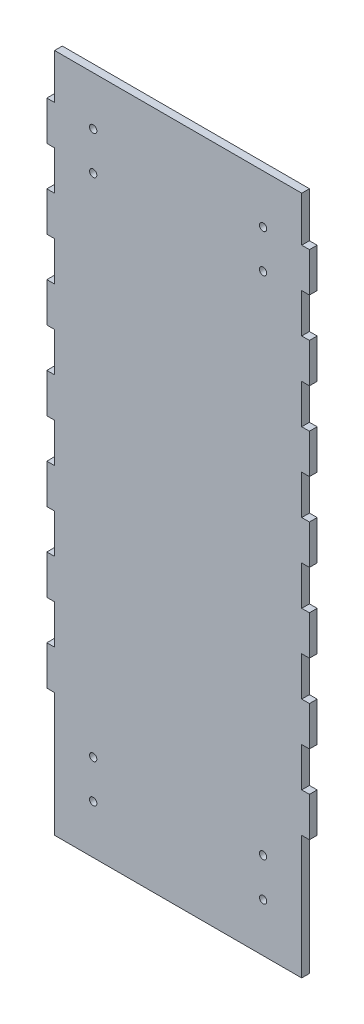
from build123d import *

# Parameters (mm, degrees)
BOSS_EXTRUDE1_DEPTH = 3.175
SKETCH2_R           = 1.5
CUT_EXTRUDE1_DEPTH  = 3.175


with BuildPart() as part:
    # Sketch1 → Boss-Extrude1 (new body)
    with BuildSketch(Plane.XY):
        Polygon((101.6, 279.4), (0, 279.4), (0, 260.883636364), (-3.175, 260.883636364), (-3.175, 244.72), (0, 244.72), (0, 228.563636364), (-3.175, 228.563636364), (-3.175, 212.4), (0, 212.4), (0, 196.243636364), (-3.175, 196.243636364), (-3.175, 180.08), (0, 180.08), (0, 163.923636364), (-3.175, 163.923636364), (-3.175, 147.76), (0, 147.76), (0, 131.603636364), (-3.175, 131.603636364), (-3.175, 115.44), (0, 115.44), (0, 99.283636364), (-3.175, 99.283636364), (-3.175, 83.12), (0, 83.12), (0, 66.963636364), (-3.175, 66.963636364), (-3.175, 50.8), (0, 50.8), (0, 34.64), (0, 0), (101.6, 0), (101.6, 34.64), (101.6, 50.8), (104.775, 50.8), (104.775, 66.963636364), (101.6, 66.963636364), (101.6, 83.12), (104.775, 83.12), (104.775, 99.283636364), (101.6, 99.283636364), (101.6, 115.44), (104.775, 115.44), (104.775, 131.603636364), (101.6, 131.603636364), (101.6, 147.76), (104.775, 147.76), (104.775, 163.923636364), (101.6, 163.923636364), (101.6, 180.08), (104.775, 180.08), (104.775, 196.243636364), (101.6, 196.243636364), (101.6, 212.4), (104.775, 212.4), (104.775, 228.563636364), (101.6, 228.563636364), (101.6, 244.72), (104.775, 244.72), (104.775, 260.883636364), (101.6, 260.883636364), align=None)
    extrude(amount=BOSS_EXTRUDE1_DEPTH)

    # Sketch2 → Cut-Extrude1 (cut)
    with BuildSketch(Plane.XY.offset(3.175)):
        with Locations((15.875, 20)):
            Circle(SKETCH2_R)
        with Locations((15.875, 35.75)):
            Circle(SKETCH2_R)
        with Locations((15.875, 243.65)):
            Circle(SKETCH2_R)
        with Locations((15.875, 259.4)):
            Circle(SKETCH2_R)
        with Locations((85.725, 259.4)):
            Circle(SKETCH2_R)
        with Locations((85.725, 243.65)):
            Circle(SKETCH2_R)
        with Locations((85.725, 35.75)):
            Circle(SKETCH2_R)
        with Locations((85.725, 20)):
            Circle(SKETCH2_R)
    extrude(amount=-CUT_EXTRUDE1_DEPTH, mode=Mode.SUBTRACT)


solid = part.part
